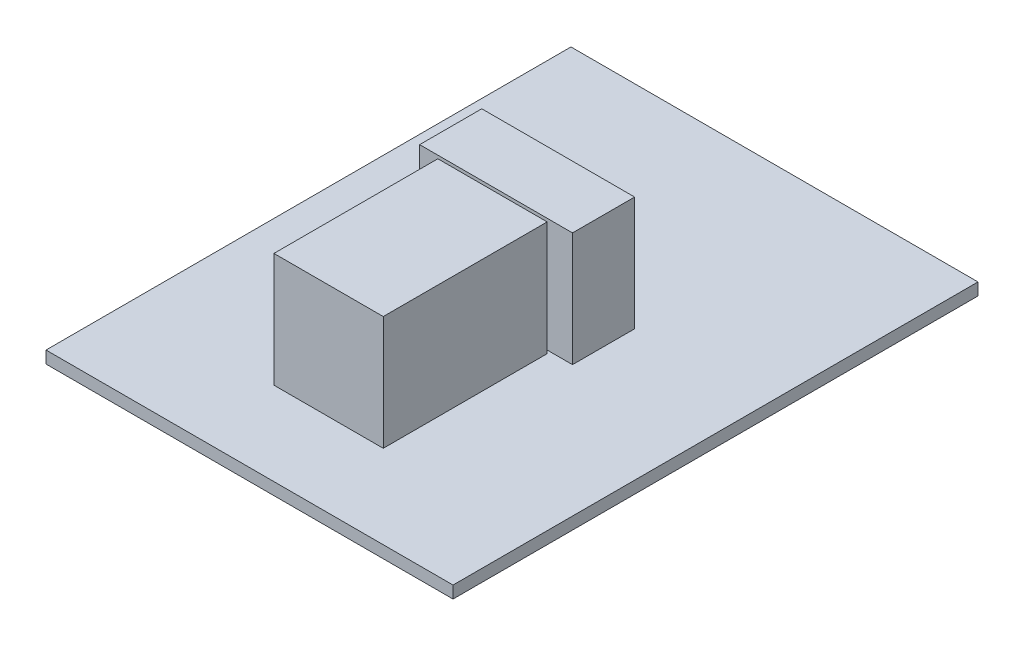
from build123d import *

# Parameters (mm, degrees)
SKETCH1_W           = 53.5
SKETCH1_H           = 69
BOSS_EXTRUDE1_DEPTH = 1.6
SKETCH2_W           = 14.370829491
SKETCH2_H           = 21.545006918
SKETCH2_W_2         = 20.091332163
SKETCH2_H_2         = 8.16381914
BOSS_EXTRUDE2_DEPTH = 15


with BuildPart() as part:
    # Sketch1 → Boss-Extrude1 (new body)
    with BuildSketch(Plane(origin=(0, 0, 0), x_dir=(1, 0, 0), z_dir=(0, 1, 0))):
        with Locations((26.75, 34.5)):
            Rectangle(SKETCH1_W, SKETCH1_H)
    extrude(amount=BOSS_EXTRUDE1_DEPTH)

    # Sketch2 → Boss-Extrude2 (add)
    with BuildSketch(Plane(origin=(0, 1.6, 0), x_dir=(1, 0, 0), z_dir=(0, 1, 0))):
        with Locations((26.167912185, 21.747332369)):
            Rectangle(SKETCH2_W, SKETCH2_H)
        with Locations((26.223532009, 37.015733034)):
            Rectangle(SKETCH2_W_2, SKETCH2_H_2)
    extrude(amount=BOSS_EXTRUDE2_DEPTH)


solid = part.part
